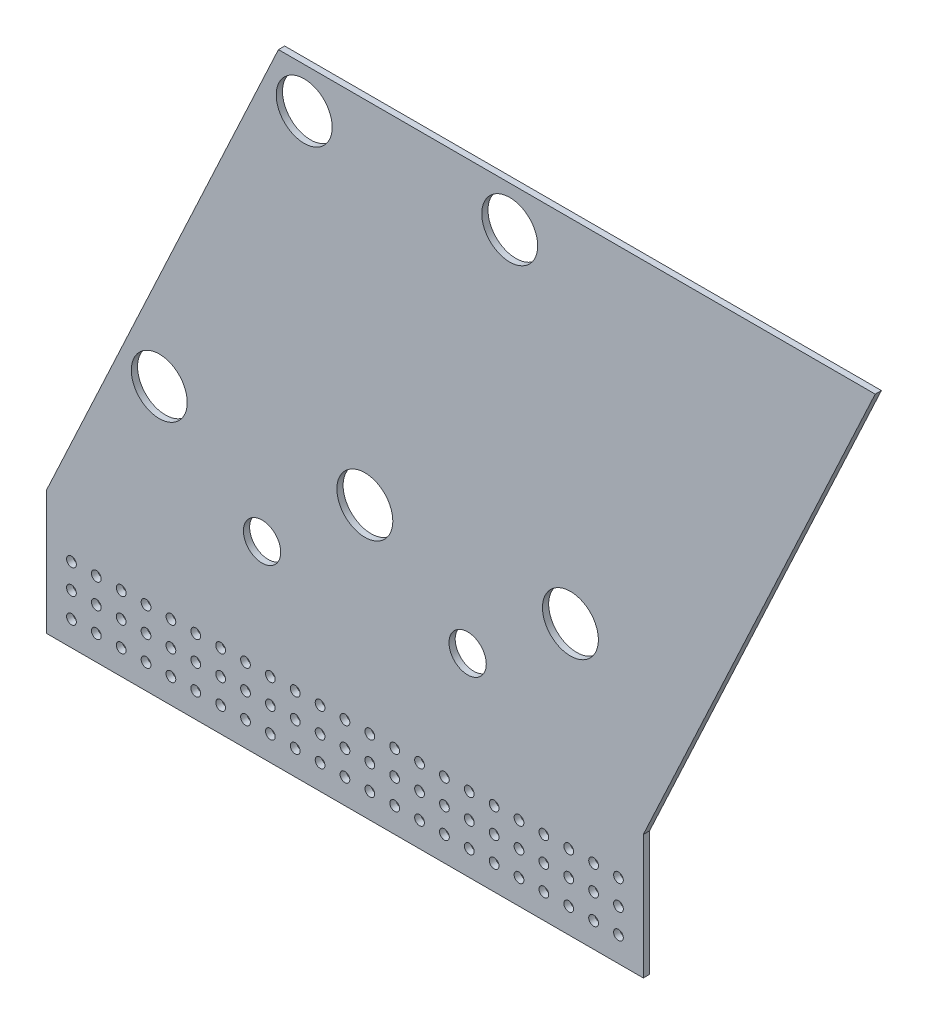
from build123d import *

# Parameters (mm, degrees)
SKETCH1_R           = 14.2875
SKETCH1_R_2         = 9.525
SKETCH1_R_3         = 2.4892
BOSS_EXTRUDE3_DEPTH = 3.175


with BuildPart() as part:
    # Sketch1 → Boss-Extrude3 (new body)
    with BuildSketch(Plane.XY):
        Polygon((93.273189322, 200.025), (-25.168955849, -53.975), (-25.168955849, -117.475), (279.631044151, -117.475), (279.631044151, -53.975), (398.073189322, 200.025), align=None)
        with Locations((32.394386098, 20.6375)):
            Circle(SKETCH1_R, mode=Mode.SUBTRACT)
        with Locations((137.394386098, 20.6375)):
            Circle(SKETCH1_R, mode=Mode.SUBTRACT)
        with Locations((242.394386098, 20.6375)):
            Circle(SKETCH1_R, mode=Mode.SUBTRACT)
        with Locations((106.42072683, 179.3875)):
            Circle(SKETCH1_R, mode=Mode.SUBTRACT)
        with Locations((211.39892683, 179.3875)):
            Circle(SKETCH1_R, mode=Mode.SUBTRACT)
        with Locations((189.894386098, -18.746667191)):
            Circle(SKETCH1_R_2, mode=Mode.SUBTRACT)
        with Locations((84.894386098, -21.788906871)):
            Circle(SKETCH1_R_2, mode=Mode.SUBTRACT)
        with Locations((266.931044151, -79.375)):
            Circle(SKETCH1_R_3, mode=Mode.SUBTRACT)
        with Locations((-12.468955849, -104.775)):
            Circle(SKETCH1_R_3, mode=Mode.SUBTRACT)
        with Locations((0.231044151, -104.775)):
            Circle(SKETCH1_R_3, mode=Mode.SUBTRACT)
        with Locations((12.931044151, -104.775)):
            Circle(SKETCH1_R_3, mode=Mode.SUBTRACT)
        with Locations((25.631044151, -104.775)):
            Circle(SKETCH1_R_3, mode=Mode.SUBTRACT)
        with Locations((-12.468955849, -92.075)):
            Circle(SKETCH1_R_3, mode=Mode.SUBTRACT)
        with Locations((0.231044151, -92.075)):
            Circle(SKETCH1_R_3, mode=Mode.SUBTRACT)
        with Locations((-12.468955849, -79.375)):
            Circle(SKETCH1_R_3, mode=Mode.SUBTRACT)
        with Locations((0.231044151, -79.375)):
            Circle(SKETCH1_R_3, mode=Mode.SUBTRACT)
        with Locations((12.931044151, -92.075)):
            Circle(SKETCH1_R_3, mode=Mode.SUBTRACT)
        with Locations((25.631044151, -92.075)):
            Circle(SKETCH1_R_3, mode=Mode.SUBTRACT)
        with Locations((12.931044151, -79.375)):
            Circle(SKETCH1_R_3, mode=Mode.SUBTRACT)
        with Locations((25.631044151, -79.375)):
            Circle(SKETCH1_R_3, mode=Mode.SUBTRACT)
        with Locations((38.331044151, -104.775)):
            Circle(SKETCH1_R_3, mode=Mode.SUBTRACT)
        with Locations((51.031044151, -104.775)):
            Circle(SKETCH1_R_3, mode=Mode.SUBTRACT)
        with Locations((63.731044151, -104.775)):
            Circle(SKETCH1_R_3, mode=Mode.SUBTRACT)
        with Locations((76.431044151, -104.775)):
            Circle(SKETCH1_R_3, mode=Mode.SUBTRACT)
        with Locations((38.331044151, -92.075)):
            Circle(SKETCH1_R_3, mode=Mode.SUBTRACT)
        with Locations((51.031044151, -92.075)):
            Circle(SKETCH1_R_3, mode=Mode.SUBTRACT)
        with Locations((38.331044151, -79.375)):
            Circle(SKETCH1_R_3, mode=Mode.SUBTRACT)
        with Locations((51.031044151, -79.375)):
            Circle(SKETCH1_R_3, mode=Mode.SUBTRACT)
        with Locations((63.731044151, -92.075)):
            Circle(SKETCH1_R_3, mode=Mode.SUBTRACT)
        with Locations((76.431044151, -92.075)):
            Circle(SKETCH1_R_3, mode=Mode.SUBTRACT)
        with Locations((63.731044151, -79.375)):
            Circle(SKETCH1_R_3, mode=Mode.SUBTRACT)
        with Locations((76.431044151, -79.375)):
            Circle(SKETCH1_R_3, mode=Mode.SUBTRACT)
        with Locations((89.131044151, -104.775)):
            Circle(SKETCH1_R_3, mode=Mode.SUBTRACT)
        with Locations((101.831044151, -104.775)):
            Circle(SKETCH1_R_3, mode=Mode.SUBTRACT)
        with Locations((114.531044151, -104.775)):
            Circle(SKETCH1_R_3, mode=Mode.SUBTRACT)
        with Locations((127.231044151, -104.775)):
            Circle(SKETCH1_R_3, mode=Mode.SUBTRACT)
        with Locations((89.131044151, -92.075)):
            Circle(SKETCH1_R_3, mode=Mode.SUBTRACT)
        with Locations((101.831044151, -92.075)):
            Circle(SKETCH1_R_3, mode=Mode.SUBTRACT)
        with Locations((89.131044151, -79.375)):
            Circle(SKETCH1_R_3, mode=Mode.SUBTRACT)
        with Locations((101.831044151, -79.375)):
            Circle(SKETCH1_R_3, mode=Mode.SUBTRACT)
        with Locations((114.531044151, -92.075)):
            Circle(SKETCH1_R_3, mode=Mode.SUBTRACT)
        with Locations((127.231044151, -92.075)):
            Circle(SKETCH1_R_3, mode=Mode.SUBTRACT)
        with Locations((114.531044151, -79.375)):
            Circle(SKETCH1_R_3, mode=Mode.SUBTRACT)
        with Locations((127.231044151, -79.375)):
            Circle(SKETCH1_R_3, mode=Mode.SUBTRACT)
        with Locations((139.931044151, -104.775)):
            Circle(SKETCH1_R_3, mode=Mode.SUBTRACT)
        with Locations((152.631044151, -104.775)):
            Circle(SKETCH1_R_3, mode=Mode.SUBTRACT)
        with Locations((165.331044151, -104.775)):
            Circle(SKETCH1_R_3, mode=Mode.SUBTRACT)
        with Locations((178.031044151, -104.775)):
            Circle(SKETCH1_R_3, mode=Mode.SUBTRACT)
        with Locations((139.931044151, -92.075)):
            Circle(SKETCH1_R_3, mode=Mode.SUBTRACT)
        with Locations((152.631044151, -92.075)):
            Circle(SKETCH1_R_3, mode=Mode.SUBTRACT)
        with Locations((139.931044151, -79.375)):
            Circle(SKETCH1_R_3, mode=Mode.SUBTRACT)
        with Locations((152.631044151, -79.375)):
            Circle(SKETCH1_R_3, mode=Mode.SUBTRACT)
        with Locations((165.331044151, -92.075)):
            Circle(SKETCH1_R_3, mode=Mode.SUBTRACT)
        with Locations((178.031044151, -92.075)):
            Circle(SKETCH1_R_3, mode=Mode.SUBTRACT)
        with Locations((165.331044151, -79.375)):
            Circle(SKETCH1_R_3, mode=Mode.SUBTRACT)
        with Locations((178.031044151, -79.375)):
            Circle(SKETCH1_R_3, mode=Mode.SUBTRACT)
        with Locations((190.731044151, -104.775)):
            Circle(SKETCH1_R_3, mode=Mode.SUBTRACT)
        with Locations((203.431044151, -104.775)):
            Circle(SKETCH1_R_3, mode=Mode.SUBTRACT)
        with Locations((216.131044151, -104.775)):
            Circle(SKETCH1_R_3, mode=Mode.SUBTRACT)
        with Locations((228.831044151, -104.775)):
            Circle(SKETCH1_R_3, mode=Mode.SUBTRACT)
        with Locations((190.731044151, -92.075)):
            Circle(SKETCH1_R_3, mode=Mode.SUBTRACT)
        with Locations((203.431044151, -92.075)):
            Circle(SKETCH1_R_3, mode=Mode.SUBTRACT)
        with Locations((190.731044151, -79.375)):
            Circle(SKETCH1_R_3, mode=Mode.SUBTRACT)
        with Locations((203.431044151, -79.375)):
            Circle(SKETCH1_R_3, mode=Mode.SUBTRACT)
        with Locations((216.131044151, -92.075)):
            Circle(SKETCH1_R_3, mode=Mode.SUBTRACT)
        with Locations((228.831044151, -92.075)):
            Circle(SKETCH1_R_3, mode=Mode.SUBTRACT)
        with Locations((216.131044151, -79.375)):
            Circle(SKETCH1_R_3, mode=Mode.SUBTRACT)
        with Locations((228.831044151, -79.375)):
            Circle(SKETCH1_R_3, mode=Mode.SUBTRACT)
        with Locations((241.531044151, -104.775)):
            Circle(SKETCH1_R_3, mode=Mode.SUBTRACT)
        with Locations((254.231044151, -104.775)):
            Circle(SKETCH1_R_3, mode=Mode.SUBTRACT)
        with Locations((266.931044151, -104.775)):
            Circle(SKETCH1_R_3, mode=Mode.SUBTRACT)
        with Locations((241.531044151, -92.075)):
            Circle(SKETCH1_R_3, mode=Mode.SUBTRACT)
        with Locations((254.231044151, -92.075)):
            Circle(SKETCH1_R_3, mode=Mode.SUBTRACT)
        with Locations((241.531044151, -79.375)):
            Circle(SKETCH1_R_3, mode=Mode.SUBTRACT)
        with Locations((254.231044151, -79.375)):
            Circle(SKETCH1_R_3, mode=Mode.SUBTRACT)
        with Locations((266.931044151, -92.075)):
            Circle(SKETCH1_R_3, mode=Mode.SUBTRACT)
    extrude(amount=BOSS_EXTRUDE3_DEPTH)


solid = part.part
